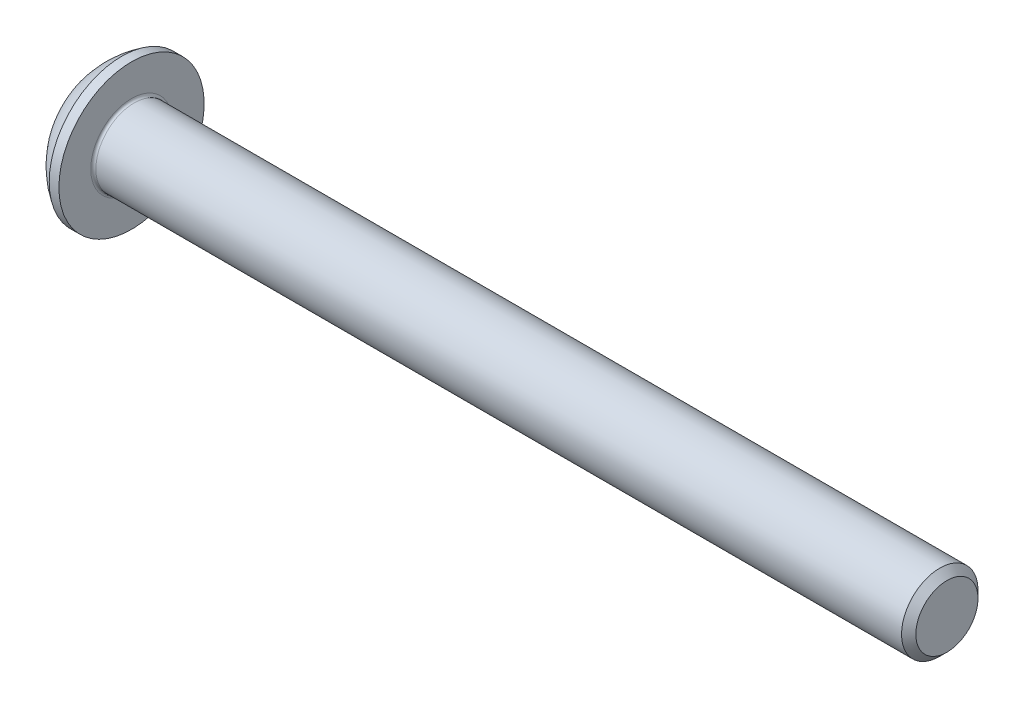
from build123d import *

# Parameters (mm, degrees)
FILLET1_R   = 0.1
HEX_2_DEPTH = 1.04


with BuildPart() as part:
    # BodySke → BaseBody (revolve)
    with BuildSketch(Plane.XY):
        with BuildLine():
            Line((33.65, 0), (33.65, 1.2195))
            Line((33.65, 1.2195), (33.3695, 1.5))
            Line((33.3695, 1.5), (1.65, 1.5))
            Line((1.65, 1.5), (1.65, 2.85))
            Line((1.65, 2.85), (1.27, 2.85))
            ThreePointArc((1.27, 2.85), (0.53140404, 2.229827628), (0, 1.425))
            Line((0, 1.425), (0, 0))
            Line((0, 0), (33.65, 0))
        make_face()
    revolve(axis=Axis((0, 0, 0), (1, 0, 0)))

    # Fillet1
    fillet1_edges = [part.edges().sort_by_distance(p)[0] for p in [
        (1.65, -1.5, 0),
    ]]
    fillet(fillet1_edges, radius=FILLET1_R)

    # Sketch2 → PreBroach (revolve, cut)
    with BuildSketch(Plane.XY):
        Polygon((0, 1), (1.04, 1), (1.617350269, 0), (0, 0), align=None)
    revolve(axis=Axis((0, 0, 0), (1, 0, 0)), mode=Mode.SUBTRACT)

    # Sketch3 → Hex 2 (cut)
    with BuildSketch(Plane(origin=(0, 0, 0), x_dir=(0, 0, -1), z_dir=(1, 0, 0))):
        Polygon((-1, -0.577350269), (-1, 0.577350269), (0, 1.154700538), (1, 0.577350269), (1, -0.577350269), (0, -1.154700538), align=None)
    extrude(amount=HEX_2_DEPTH, mode=Mode.SUBTRACT)


solid = part.part
